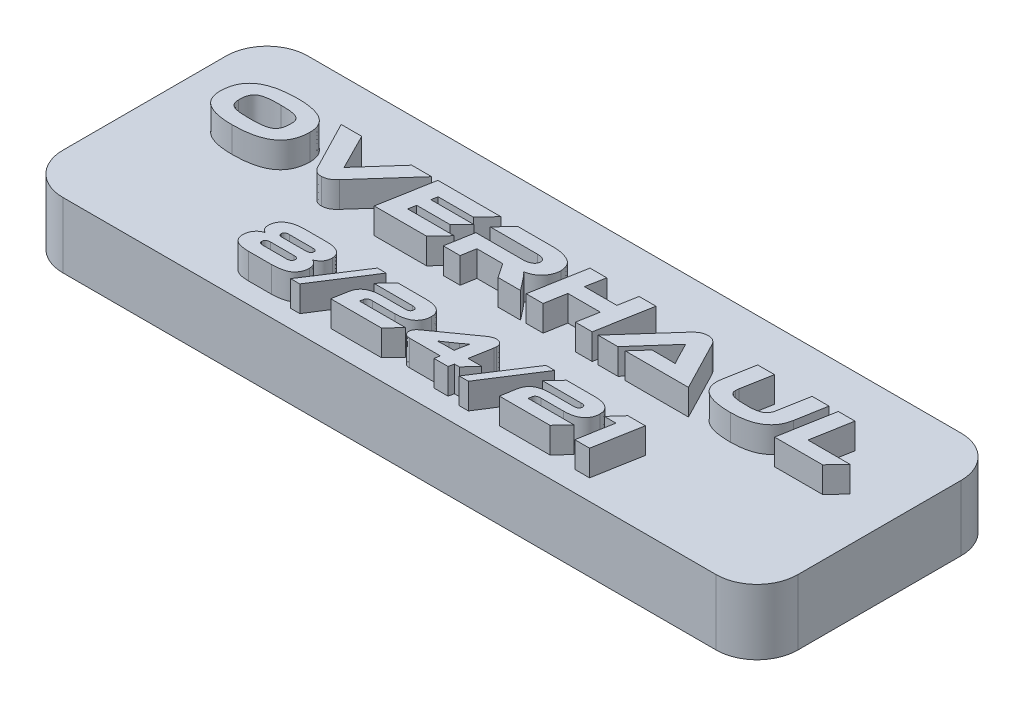
from build123d import *

# Parameters (mm, degrees)
SKETCH1_W           = 57.15
SKETCH1_H           = 19.05
BOSS_EXTRUDE1_DEPTH = 5.08
FILLET1_R           = 3.175
BOSS_EXTRUDE2_DEPTH = 2
SKETCH4_R           = 0.9
CUT_EXTRUDE1_DEPTH  = 4


with BuildPart() as part:
    # Sketch1 → Boss-Extrude1 (new body)
    with BuildSketch(Plane(origin=(0, 0, 0), x_dir=(1, 0, 0), z_dir=(0, 1, 0))):
        Rectangle(SKETCH1_W, SKETCH1_H)
    extrude(amount=BOSS_EXTRUDE1_DEPTH)

    # Fillet1
    fillet1_edges = [part.edges().sort_by_distance(p)[0] for p in [
        (-28.575, 2.54, -9.525),
        (-28.575, 2.54, 9.525),
        (28.575, 2.54, 9.525),
        (28.575, 2.54, -9.525),
    ]]
    fillet(fillet1_edges, radius=FILLET1_R)

    # Sketch3 → Boss-Extrude2 (add)
    with BuildSketch(Plane(origin=(0, 5.08, 0), x_dir=(1, 0, 0), z_dir=(0, 1, 0))):
        Polygon((21.904636604, 1.105536066), (22.460685417, 4.208766837), (21.159025697, 4.208766837), (20.407096052, 0.006075914), (24.141469328, 0.006075914), (25.184060852, 1.105536066), align=None)
        with BuildLine():
            Line((20.442064251, 4.208766837), (19.127767057, 4.208766837))
            Line((19.127767057, 4.208766837), (18.704411711, 1.862388219))
            add(Edge.make_bspline(
                [(18.704411711, 1.862388219), (18.697687187, 1.827139312), (18.684654402, 1.758823487), (18.656333037, 1.660431879), (18.619027642, 1.570400798), (18.573699748, 1.487363307), (18.519777, 1.412619114), (18.457889435, 1.344995689), (18.387796129, 1.285307175), (18.309190758, 1.232427909), (18.219374333, 1.187314428), (18.117870887, 1.147991514), (18.002759909, 1.116850242), (17.875153325, 1.090400749), (17.73446191, 1.069568326), (17.580667265, 1.055333672), (17.413824815, 1.047035371), (17.298252538, 1.046819269), (17.238213092, 1.046707005)],
                knots=[0, 0, 0, 0, 0.000107621, 0.000208581, 0.000306536, 0.000399412, 0.000491759, 0.000582339, 0.000673759, 0.000767316, 0.000865846, 0.000974664, 0.001093329, 0.001223132, 0.001365473, 0.001519746, 0.001686326, 0.001866423, 0.001866423, 0.001866423, 0.001866423], degree=3))
            add(Edge.make_bspline(
                [(17.238213092, 1.046707005), (17.169950394, 1.046621121), (17.038884397, 1.046456221), (16.850538645, 1.052429953), (16.678498084, 1.060533552), (16.523041839, 1.075472065), (16.384262724, 1.093422131), (16.261547536, 1.114517759), (16.15566669, 1.141999094), (16.064276341, 1.172526408), (15.987045543, 1.209629908), (15.920884102, 1.251845467), (15.865525046, 1.30043275), (15.820735287, 1.354972316), (15.787254953, 1.415773277), (15.764123896, 1.4824615), (15.75234608, 1.555465653), (15.752587531, 1.605828027), (15.752711884, 1.631765942)],
                knots=[0, 0, 0, 0, 0.000204773, 0.000393168, 0.000565272, 0.000721365, 0.000861515, 0.000985061, 0.001094592, 0.001189417, 0.001273644, 0.00135098, 0.001424164, 0.001493694, 0.001561619, 0.001631293, 0.001704482, 0.001782207, 0.001782207, 0.001782207, 0.001782207], degree=3))
            add(Edge.make_bspline(
                [(15.752711884, 1.631765942), (15.753573907, 1.668081018), (15.755405459, 1.745240135), (15.766196769, 1.821673195), (15.77190913, 1.862132899)],
                knots=[0, 0, 0, 0, 0.00010888, 0.00023134, 0.00023134, 0.00023134, 0.00023134], degree=3))
            Line((15.77190913, 1.862132899), (16.202192054, 4.208766837))
            Line((16.202192054, 4.208766837), (14.894213597, 4.208766837))
            Line((14.894213597, 4.208766837), (14.470858251, 1.862388219))
            add(Edge.make_bspline(
                [(14.470858251, 1.862388219), (14.459517189, 1.795424142), (14.437513802, 1.665503639), (14.434252842, 1.533787249), (14.432672657, 1.46996058)],
                knots=[0, 0, 0, 0, 0.000203453, 0.00039473, 0.00039473, 0.00039473, 0.00039473], degree=3))
            add(Edge.make_bspline(
                [(14.432672657, 1.46996058), (14.43387161, 1.40859245), (14.436205976, 1.289108399), (14.465425441, 1.115562884), (14.513284004, 0.953539335), (14.583011741, 0.803554728), (14.67195073, 0.665184035), (14.782704836, 0.540177804), (14.911738014, 0.425561456), (15.062393294, 0.324145254), (15.233636323, 0.234151547), (15.427444459, 0.15809302), (15.642905635, 0.09238014), (15.881057591, 0.039293588), (16.141111837, -0.002721651), (16.423517594, -0.030740825), (16.728165043, -0.049583047), (16.938948754, -0.051848282), (17.048068937, -0.053020966)],
                knots=[0, 0, 0, 0, 0.000183929, 0.000358111, 0.000526139, 0.000689333, 0.000852629, 0.001017828, 0.001188792, 0.001369069, 0.001561259, 0.001768019, 0.001992702, 0.002236425, 0.002499429, 0.002782504, 0.003087466, 0.003414796, 0.003414796, 0.003414796, 0.003414796], degree=3))
            add(Edge.make_bspline(
                [(17.048068937, -0.053020966), (17.155069055, -0.051404013), (17.363226566, -0.0482584), (17.666249847, -0.025020937), (17.951508656, 0.011650769), (18.218753707, 0.064516757), (18.468170696, 0.131877218), (18.699745928, 0.213665603), (18.912822065, 0.311958663), (19.108558509, 0.424179889), (19.286111022, 0.552059501), (19.446493896, 0.694108361), (19.587957265, 0.852282745), (19.710910661, 1.025501425), (19.817027583, 1.21259616), (19.902209005, 1.415894135), (19.973306285, 1.632639003), (20.003011476, 1.784635018), (20.018157198, 1.862132899)],
                knots=[0, 0, 0, 0, 0.000320974, 0.000624421, 0.000911183, 0.001183331, 0.001441019, 0.001685636, 0.00191919, 0.002144039, 0.002361465, 0.002574487, 0.002785536, 0.002996585, 0.003210663, 0.003429366, 0.003656887, 0.00389357, 0.00389357, 0.00389357, 0.00389357], degree=3))
            Line((20.018157198, 1.862132899), (20.442064251, 4.208766837))
        make_face()
        with BuildLine():
            Line((13.713425825, 0.006075914), (11.748298771, 3.800574494))
            add(Edge.make_bspline(
                [(11.748298771, 3.800574494), (11.730177827, 3.832806008), (11.694219163, 3.896765269), (11.629345474, 3.985575321), (11.552085987, 4.0630874), (11.467183075, 4.133983071), (11.369377181, 4.192399523), (11.257266032, 4.23493807), (11.131224204, 4.260058315), (11.042493271, 4.264204191), (10.996365556, 4.266359469)],
                knots=[0, 0, 0, 0, 0.000110886, 0.000220038, 0.000328642, 0.000438436, 0.000551159, 0.000668641, 0.000796469, 0.000934872, 0.000934872, 0.000934872, 0.000934872], degree=3))
            add(Edge.make_bspline(
                [(10.996365556, 4.266359469), (10.946553896, 4.264009128), (10.849822775, 4.259444915), (10.709784019, 4.230967468), (10.579505457, 4.187726952), (10.459770582, 4.126959855), (10.350088926, 4.055096369), (10.246887573, 3.977511138), (10.15258136, 3.892229282), (10.095198857, 3.830720556), (10.066670338, 3.800140628)],
                knots=[0, 0, 0, 0, 0.00014941, 0.000290146, 0.000427171, 0.000560039, 0.000691642, 0.000820174, 0.000947034, 0.001072464, 0.001072464, 0.001072464, 0.001072464], degree=3))
            Line((10.066670338, 3.800140628), (6.680672092, 0.006075914))
            Line((6.680672092, 0.006075914), (8.228762536, 0.006075914))
            Line((8.228762536, 0.006075914), (10.705707247, 2.798493231))
            Line((10.705707247, 2.798493231), (11.268074796, 1.696826253))
            add(Edge.make_bspline(
                [(11.268074796, 1.696826253), (11.294748801, 1.644325557), (11.349265048, 1.5370248), (11.418693389, 1.403208105), (11.474776483, 1.297464771), (11.515917598, 1.223921613), (11.552321439, 1.155498073), (11.577619745, 1.112747401), (11.589651884, 1.092414734)],
                knots=[0, 0, 0, 0, 0.000176664, 0.000361065, 0.000452265, 0.000535729, 0.000613867, 0.000684736, 0.000684736, 0.000684736, 0.000684736], degree=3))
            add(Edge.make_bspline(
                [(11.589651884, 1.092414734), (11.534203539, 1.095166522), (11.416043704, 1.101030553), (11.231613169, 1.103502684), (11.036594303, 1.10564963), (10.904341706, 1.105358474), (10.838216812, 1.105212899)],
                knots=[0, 0, 0, 0, 0.000166537, 0.000354888, 0.000553268, 0.00075164, 0.00075164, 0.00075164, 0.00075164], degree=3))
            Line((10.838216812, 1.105212899), (9.783171717, 1.105536066))
            Line((9.783171717, 1.105536066), (8.797448822, 0.006075914))
            Line((8.797448822, 0.006075914), (13.713425825, 0.006075914))
        make_face()
        Polygon((6.982894813, 4.208766837), (5.674916356, 4.208766837), (5.409529423, 2.743700198), (2.888353556, 2.743700198), (3.160059226, 4.208766837), (1.852080769, 4.208766837), (1.100151125, 0.003655726), (2.414448318, 0.003655726), (2.698791461, 1.644240046), (5.219967327, 1.644240046), (4.929305448, 0.003655726), (6.230965169, 0.003655726), align=None)
        with BuildLine():
            add(Edge.make_bspline(
                [(0.022791374, 0.821261664), (-0.004994751, 0.855514425), (-0.057904322, 0.920737585), (-0.131689663, 1.014147602), (-0.200292848, 1.094728322), (-0.260658939, 1.165931133), (-0.316640074, 1.228233858), (-0.36814445, 1.283693514), (-0.416727333, 1.332710365), (-0.449031208, 1.361916294), (-0.464390531, 1.375802657)],
                knots=[0, 0, 0, 0, 0.000132319, 0.000251958, 0.000357066, 0.000449775, 0.000531993, 0.000608312, 0.000676831, 0.00073894, 0.00073894, 0.00073894, 0.00073894], degree=3))
            add(Edge.make_bspline(
                [(-0.464390531, 1.375802657), (-0.413945609, 1.387655917), (-0.314612899, 1.41099655), (-0.170645879, 1.456505146), (-0.034807147, 1.512656797), (0.093162396, 1.577599655), (0.213949002, 1.650662326), (0.325673422, 1.734287933), (0.429411301, 1.827209607), (0.524966768, 1.928008098), (0.610833583, 2.036209783), (0.687047191, 2.148795776), (0.750293461, 2.26744033), (0.803959406, 2.389702633), (0.844461788, 2.517720245), (0.876615568, 2.649747841), (0.894225263, 2.787111939), (0.898356707, 2.88015474), (0.900442271, 2.927122995)],
                knots=[0, 0, 0, 0, 0.000155422, 0.000306047, 0.000452383, 0.000595882, 0.000736201, 0.000875336, 0.001013884, 0.001153561, 0.001291475, 0.00142788, 0.00156081, 0.001694289, 0.00182785, 0.001963107, 0.002101444, 0.002242464, 0.002242464, 0.002242464, 0.002242464], degree=3))
            add(Edge.make_bspline(
                [(0.900442271, 2.927122995), (0.895778624, 2.986733362), (0.886779663, 3.101757358), (0.850373496, 3.266295736), (0.797787855, 3.416602664), (0.72682639, 3.55250609), (0.638298171, 3.674215745), (0.530496428, 3.779555576), (0.407150888, 3.872802597), (0.265519129, 3.946152329), (0.115725482, 4.009923214), (-0.038563888, 4.066098529), (-0.196681704, 4.111445148), (-0.357669337, 4.149301444), (-0.522236672, 4.17747869), (-0.689778911, 4.196572697), (-0.860386404, 4.207081738), (-0.975084963, 4.20637971), (-1.032994686, 4.206025266)],
                knots=[0, 0, 0, 0, 0.000179195, 0.000345775, 0.000503934, 0.000655634, 0.000804102, 0.000953423, 0.00110627, 0.001266195, 0.001430402, 0.00159465, 0.001758393, 0.001923592, 0.002090563, 0.002258951, 0.002429281, 0.002602973, 0.002602973, 0.002602973, 0.002602973], degree=3))
            Line((-1.032994686, 4.206025266), (-3.749494321, 4.206347541))
            Line((-3.749494321, 4.206347541), (-4.798404581, 3.106887389))
            Line((-4.798404581, 3.106887389), (-1.120899934, 3.106887389))
            add(Edge.make_bspline(
                [(-1.120899934, 3.106887389), (-1.072938384, 3.105563142), (-0.982126628, 3.103055777), (-0.854021817, 3.084102014), (-0.742401524, 3.053127658), (-0.648041951, 3.008361144), (-0.571875632, 2.950733271), (-0.51613922, 2.878524615), (-0.482912556, 2.792039639), (-0.479147209, 2.729960255), (-0.477188696, 2.697670193)],
                knots=[0, 0, 0, 0, 0.000143839, 0.000272348, 0.000387495, 0.000490117, 0.000583924, 0.00067132, 0.000760449, 0.00085706, 0.00085706, 0.00085706, 0.00085706], degree=3))
            add(Edge.make_bspline(
                [(-0.477188696, 2.697670193), (-0.478865735, 2.677195647), (-0.482173726, 2.636809238), (-0.494954964, 2.578009425), (-0.515063441, 2.522994029), (-0.542454382, 2.47158108), (-0.575845759, 2.423095084), (-0.617782693, 2.378841184), (-0.666800829, 2.338813063), (-0.740479044, 2.288346001), (-0.845093422, 2.236864834), (-0.982572599, 2.191707585), (-1.133178036, 2.165412454), (-1.237662961, 2.161339559), (-1.291700435, 2.15923314)],
                knots=[0, 0, 0, 0, 6.1582e-05, 0.000121471, 0.000179891, 0.000236731, 0.000295819, 0.000355966, 0.000418937, 0.000485369, 0.000623551, 0.000766937, 0.000918284, 0.001080402, 0.001080402, 0.001080402, 0.001080402], degree=3))
            Line((-1.291700435, 2.15923314), (-4.969010467, 2.159459893))
            Line((-4.969010467, 2.159459893), (-5.348134658, 0.003655726))
            Line((-5.348134658, 0.003655726), (-4.040156201, 0.003655726))
            Line((-4.040156201, 0.003655726), (-3.844275369, 1.11686837))
            Line((-3.844275369, 1.11686837), (-1.834917159, 1.11686837))
            Line((-1.834917159, 1.11686837), (-1.089306252, 0.003655726))
            Line((-1.089306252, 0.003655726), (0.660983761, 0.003655726))
            Line((0.660983761, 0.003655726), (0.022791374, 0.821261664))
        make_face()
        Polygon((-9.214180118, 1.105536066), (-9.113080334, 1.700326644), (-6.509760893, 1.700326644), (-5.599862836, 2.629107706), (-8.942474448, 2.629107706), (-8.854012137, 3.106887389), (-6.117999229, 3.106887389), (-5.075407706, 4.206347541), (-9.966109762, 4.206347541), (-10.718039407, 0.006075914), (-6.648773096, 0.006075914), (-5.612500309, 1.105536066), align=None)
        with BuildLine():
            Line((-17.490908988, 4.208766837), (-15.525781935, 0.415372562))
            add(Edge.make_bspline(
                [(-15.525781935, 0.415372562), (-15.508050787, 0.382479631), (-15.473037945, 0.317527547), (-15.4071602, 0.228997354), (-15.33127617, 0.149963013), (-15.246514412, 0.078477155), (-15.148276801, 0.019758241), (-15.035586647, -0.022115586), (-14.909528353, -0.048687381), (-14.820715584, -0.053343833), (-14.774566473, -0.05576343)],
                knots=[0, 0, 0, 0, 0.000111991, 0.000221144, 0.000329771, 0.000440145, 0.000552868, 0.000671204, 0.000799219, 0.000937691, 0.000937691, 0.000937691, 0.000937691], degree=3))
            add(Edge.make_bspline(
                [(-14.774566473, -0.05576343), (-14.724766829, -0.052994881), (-14.627782225, -0.047603143), (-14.48761636, -0.019769924), (-14.357242834, 0.02385057), (-14.237962772, 0.085532414), (-14.128203214, 0.158182508), (-14.025425378, 0.236849256), (-13.930488306, 0.321749072), (-13.873915254, 0.384048841), (-13.845785411, 0.415026184)],
                knots=[0, 0, 0, 0, 0.00014948, 0.000291112, 0.000427272, 0.000560551, 0.000692652, 0.000821739, 0.000948599, 0.001074061, 0.001074061, 0.001074061, 0.001074061], degree=3))
            Line((-13.845785411, 0.415026184), (-10.458155256, 4.208766837))
            Line((-10.458155256, 4.208766837), (-12.0062457, 4.208766837))
            Line((-12.0062457, 4.208766837), (-14.483190411, 1.424784024))
            Line((-14.483190411, 1.424784024), (-15.892268652, 4.208766837))
            Line((-15.892268652, 4.208766837), (-17.490908988, 4.208766837))
        make_face()
        with BuildLine():
            add(Edge.make_bspline(
                [(-20.927025046, 4.264853435), (-21.00009776, 4.264150041), (-21.143601871, 4.262768679), (-21.355063502, 4.255304453), (-21.55933924, 4.243828802), (-21.756533388, 4.226275073), (-21.946760701, 4.204448808), (-22.130065277, 4.178135377), (-22.306362027, 4.146346882), (-22.475499423, 4.108703546), (-22.637475523, 4.066841285), (-22.792338087, 4.020018599), (-22.940547846, 3.969271115), (-23.081806941, 3.912462076), (-23.21570116, 3.850145336), (-23.343470625, 3.784672178), (-23.463519889, 3.713307743), (-23.576008698, 3.636054084), (-23.682534531, 3.555015487), (-23.78125525, 3.467997248), (-23.873108766, 3.375795294), (-23.959180076, 3.27972572), (-24.036921174, 3.176938462), (-24.109606416, 3.070861845), (-24.173047187, 2.958180712), (-24.232575897, 2.842029764), (-24.283268707, 2.71956376), (-24.326986557, 2.592115874), (-24.364923815, 2.460138961), (-24.394589245, 2.322911611), (-24.418464623, 2.180763117), (-24.435794158, 2.033740252), (-24.446118596, 1.881481624), (-24.446859522, 1.778351657), (-24.447236184, 1.725923865)],
                knots=[0, 0, 0, 0, 0.00021922, 0.000430517, 0.000634719, 0.000832939, 0.001024345, 0.001209088, 0.001388397, 0.001561619, 0.0017288, 0.001890173, 0.002046865, 0.002198625, 0.002346687, 0.00248979, 0.002629165, 0.002765325, 0.002898982, 0.003030471, 0.003159752, 0.003289265, 0.003417071, 0.003546125, 0.003674706, 0.003804712, 0.003937476, 0.004071906, 0.004208776, 0.004349179, 0.004492852, 0.004641052, 0.004793135, 0.004950393, 0.004950393, 0.004950393, 0.004950393], degree=3))
            add(Edge.make_bspline(
                [(-24.447236184, 1.725923865), (-24.445307742, 1.652651179), (-24.441566524, 1.510500548), (-24.407527654, 1.304743113), (-24.3543388, 1.113533359), (-24.278641875, 0.936607339), (-24.181089217, 0.774301847), (-24.06125441, 0.627005612), (-23.919297146, 0.495143384), (-23.756407561, 0.377875494), (-23.571969391, 0.275513814), (-23.366545115, 0.187096535), (-23.140360604, 0.111278664), (-22.892532815, 0.05083109), (-22.624087172, 0.003624777), (-22.334401862, -0.029580863), (-22.023495359, -0.049844784), (-21.809018391, -0.051940053), (-21.698373333, -0.053020966)],
                knots=[0, 0, 0, 0, 0.000219671, 0.000426167, 0.000623813, 0.000813827, 0.001001645, 0.001190103, 0.001381548, 0.00158123, 0.001790776, 0.002013083, 0.002251287, 0.002505594, 0.002777627, 0.003068474, 0.003379936, 0.003711836, 0.003711836, 0.003711836, 0.003711836], degree=3))
            add(Edge.make_bspline(
                [(-21.698373333, -0.053020966), (-21.625538667, -0.052455169), (-21.482270661, -0.051342229), (-21.270750047, -0.043724787), (-21.06646016, -0.032438481), (-20.869292668, -0.014624257), (-20.678970802, 0.006825126), (-20.49579905, 0.034388638), (-20.319463816, 0.066140884), (-20.150597896, 0.103671999), (-19.988417163, 0.145843098), (-19.832905685, 0.191939017), (-19.68486263, 0.24436261), (-19.543586925, 0.30061376), (-19.410003746, 0.363320067), (-19.282591949, 0.429548791), (-19.162841526, 0.501958418), (-19.050063375, 0.579052293), (-18.943633258, 0.660209293), (-18.844528177, 0.747143393), (-18.753319362, 0.84029394), (-18.666891877, 0.93631177), (-18.589196176, 1.03914999), (-18.516538914, 1.145233071), (-18.452806255, 1.258074334), (-18.393784926, 1.374784654), (-18.342807579, 1.497412041), (-18.299135236, 1.624884051), (-18.261200028, 1.756856749), (-18.231413982, 1.894369804), (-18.207745569, 2.036857562), (-18.190303388, 2.184166254), (-18.180000167, 2.336428379), (-18.179256314, 2.439557863), (-18.178878164, 2.491985411)],
                knots=[0, 0, 0, 0, 0.0002185, 0.000429796, 0.000634912, 0.000832221, 0.001023627, 0.001209407, 0.001387817, 0.001561039, 0.001728219, 0.001890468, 0.002047461, 0.002199222, 0.002346454, 0.00248998, 0.002629824, 0.002765984, 0.002899642, 0.003031131, 0.00316106, 0.003290573, 0.003418378, 0.003547433, 0.003676014, 0.003806837, 0.003939601, 0.004074031, 0.004210901, 0.004351303, 0.004495879, 0.004644079, 0.004796161, 0.00495342, 0.00495342, 0.00495342, 0.00495342], degree=3))
            add(Edge.make_bspline(
                [(-18.178878164, 2.491985411), (-18.180959096, 2.564930001), (-18.185011537, 2.706983534), (-18.217142892, 2.912703512), (-18.271140178, 3.104122883), (-18.347129198, 3.280748696), (-18.44508266, 3.44245971), (-18.564221655, 3.589369287), (-18.70563089, 3.721034434), (-18.869142824, 3.837071522), (-19.053175604, 3.940135668), (-19.259218181, 4.0266221), (-19.485084986, 4.102333874), (-19.733102972, 4.161421518), (-20.00172148, 4.208718585), (-20.291677839, 4.242297194), (-20.60265844, 4.261022072), (-20.817102838, 4.263336881), (-20.927025046, 4.264853435)],
                knots=[0, 0, 0, 0, 0.000218758, 0.000426013, 0.00062278, 0.000813995, 0.001001031, 0.001188203, 0.001379648, 0.001578795, 0.001788342, 0.002011126, 0.002248172, 0.002502261, 0.002775194, 0.003066041, 0.003377445, 0.003709345, 0.003709345, 0.003709345, 0.003709345], degree=3))
        make_face()
        with BuildLine():
            add(Edge.make_bspline(
                [(-21.508348804, 1.047030173), (-21.576869442, 1.04660261), (-21.708788696, 1.045779446), (-21.899648519, 1.049733712), (-22.075812928, 1.061186797), (-22.23791658, 1.075736974), (-22.385584603, 1.097737934), (-22.518911321, 1.125013299), (-22.638751052, 1.156348623), (-22.744616661, 1.194530349), (-22.838465358, 1.240026498), (-22.918360742, 1.297252332), (-22.986966727, 1.363776891), (-23.040869713, 1.441900597), (-23.083739663, 1.529303822), (-23.113564373, 1.627061382), (-23.131149478, 1.735031597), (-23.132158044, 1.81026116), (-23.132681884, 1.849334734)],
                knots=[0, 0, 0, 0, 0.000205565, 0.000395764, 0.000572537, 0.000735087, 0.000883892, 0.001020147, 0.001143219, 0.001255139, 0.001357344, 0.001455005, 0.001548736, 0.001642574, 0.001738242, 0.001839729, 0.001948086, 0.002065187, 0.002065187, 0.002065187, 0.002065187], degree=3))
            add(Edge.make_bspline(
                [(-23.132681884, 1.849334734), (-23.134330404, 1.911811071), (-23.137486254, 2.031412847), (-23.125588469, 2.203375738), (-23.100627455, 2.359667266), (-23.061778776, 2.50079582), (-23.008513485, 2.626166729), (-22.942948871, 2.737052728), (-22.861136723, 2.83042282), (-22.781930642, 2.895436203), (-22.711279894, 2.940784123), (-22.650782812, 2.971515459), (-22.583692287, 2.999666566), (-22.51042743, 3.026084681), (-22.430909795, 3.05083148), (-22.344852997, 3.072755525), (-22.251912895, 3.09131218), (-22.152820496, 3.110411596), (-22.046486912, 3.124111193), (-21.934104714, 3.137374608), (-21.814853701, 3.147018552), (-21.689292346, 3.155167115), (-21.557042952, 3.161792983), (-21.418358802, 3.165320712), (-21.272985167, 3.166041701), (-21.173952762, 3.165221911), (-21.123370097, 3.164803188)],
                knots=[0, 0, 0, 0, 0.000187411, 0.00035877, 0.00051627, 0.000661555, 0.000796714, 0.00092386, 0.001046319, 0.001167112, 0.001230003, 0.001297872, 0.001370374, 0.001448163, 0.001531436, 0.001620123, 0.001714428, 0.001815734, 0.00192278, 0.002035947, 0.002155212, 0.002281633, 0.002413427, 0.002552426, 0.00269778, 0.002849532, 0.002849532, 0.002849532, 0.002849532], degree=3))
            add(Edge.make_bspline(
                [(-21.123370097, 3.164803188), (-21.054504847, 3.165086646), (-20.921327, 3.165634822), (-20.728904532, 3.161832074), (-20.551211942, 3.150341942), (-20.387916979, 3.135653139), (-20.239267652, 3.114010286), (-20.105133317, 3.086275793), (-19.985099312, 3.055550786), (-19.879479185, 3.01670025), (-19.785930657, 2.971781209), (-19.706686234, 2.913989507), (-19.638360181, 2.847457656), (-19.583162772, 2.770130915), (-19.541516519, 2.682069422), (-19.512759707, 2.584313015), (-19.494901811, 2.476491904), (-19.493934748, 2.401253582), (-19.493432464, 2.362175459)],
                knots=[0, 0, 0, 0, 0.000206599, 0.00039954, 0.000577225, 0.000740685, 0.000891298, 0.001027553, 0.001151508, 0.001262569, 0.001364775, 0.001461693, 0.001555424, 0.00164979, 0.00174506, 0.001846279, 0.001954636, 0.002071737, 0.002071737, 0.002071737, 0.002071737], degree=3))
            add(Edge.make_bspline(
                [(-19.493432464, 2.362175459), (-19.49181009, 2.300007823), (-19.488704956, 2.181022384), (-19.500276656, 2.009565903), (-19.526503449, 1.85401663), (-19.565436613, 1.713235889), (-19.61833124, 1.587793863), (-19.685099404, 1.477427264), (-19.767128397, 1.383606431), (-19.84659497, 1.317707612), (-19.918333377, 1.272767382), (-19.979178401, 1.241979786), (-20.04584798, 1.212524455), (-20.11963264, 1.186264377), (-20.199498632, 1.161664348), (-20.286241969, 1.139884782), (-20.379158667, 1.119635522), (-20.47899588, 1.102726509), (-20.584997814, 1.086938186), (-20.697815062, 1.074209563), (-20.817051568, 1.064550242), (-20.942913099, 1.056272217), (-21.075167286, 1.049750773), (-21.214154314, 1.046182113), (-21.359528347, 1.045470465), (-21.458560697, 1.046288949), (-21.508348804, 1.047030173)],
                knots=[0, 0, 0, 0, 0.000186496, 0.000356944, 0.000514595, 0.000659, 0.000794159, 0.000921781, 0.00104424, 0.00116632, 0.001229983, 0.001297853, 0.001370716, 0.001448505, 0.001532652, 0.001621339, 0.001716727, 0.001817873, 0.001925047, 0.002038214, 0.00215839, 0.002283899, 0.002416606, 0.002555606, 0.002700959, 0.002852711, 0.002852711, 0.002852711, 0.002852711], degree=3))
        make_face(mode=Mode.SUBTRACT)
        Polygon((12.398460647, -5.218973535), (13.299670441, -5.218973535), (12.818656624, -7.93430124), (13.963137774, -7.93430124), (14.621076213, -4.256945902), (13.266497074, -4.256945902), align=None)
        with BuildLine():
            Line((7.581851533, -5.218973535), (10.572983428, -5.218973535))
            add(Edge.make_bspline(
                [(10.572983428, -5.218973535), (10.600684342, -5.218922741), (10.652530716, -5.218827674), (10.725259719, -5.225918073), (10.786783761, -5.242216387), (10.838614298, -5.26353583), (10.878707687, -5.294908436), (10.907021686, -5.334273792), (10.924573664, -5.381008794), (10.925798363, -5.4147712), (10.926432729, -5.432259348)],
                knots=[0, 0, 0, 0, 8.3099e-05, 0.000155531, 0.000218392, 0.000273538, 0.000322508, 0.000368908, 0.000417497, 0.000469711, 0.000469711, 0.000469711, 0.000469711], degree=3))
            add(Edge.make_bspline(
                [(10.926432729, -5.432259348), (10.925792936, -5.458018948), (10.924583331, -5.506720508), (10.904020946, -5.573936821), (10.87073457, -5.630194031), (10.821520946, -5.673414306), (10.757989848, -5.704561408), (10.680255681, -5.726311626), (10.587130521, -5.738498194), (10.520128877, -5.73961472), (10.484096178, -5.740215175)],
                knots=[0, 0, 0, 0, 7.6993e-05, 0.000145564, 0.000208395, 0.000270703, 0.000339032, 0.00041902, 0.000511893, 0.000619952, 0.000619952, 0.000619952, 0.000619952], degree=3))
            Line((10.484096178, -5.740215175), (8.726332683, -5.739416071))
            add(Edge.make_bspline(
                [(8.726332683, -5.739416071), (8.670730527, -5.740560639), (8.562477365, -5.742789025), (8.404482039, -5.753609346), (8.255762679, -5.772857955), (8.116139811, -5.798779792), (7.985876613, -5.833149331), (7.864797761, -5.875619954), (7.752530381, -5.92500466), (7.649328513, -5.98174212), (7.555859317, -6.047028209), (7.471333824, -6.120143527), (7.395933215, -6.201107035), (7.329932192, -6.289606037), (7.273550619, -6.385733808), (7.226454864, -6.489539314), (7.187507501, -6.600822081), (7.170185825, -6.678800473), (7.161372784, -6.718474855)],
                knots=[0, 0, 0, 0, 0.000166829, 0.000324804, 0.000474816, 0.000616477, 0.000750546, 0.000878553, 0.001001026, 0.001118108, 0.001231277, 0.001342418, 0.001452782, 0.001562526, 0.00167296, 0.001786425, 0.001904052, 0.002025887, 0.002025887, 0.002025887, 0.002025887], degree=3))
            Line((7.161372784, -6.718474855), (6.946028672, -7.932183575))
            Line((6.946028672, -7.932183575), (10.882601517, -7.932183575))
            Line((10.882601517, -7.932183575), (11.789340205, -6.970155942))
            Line((11.789340205, -6.970155942), (8.217674395, -6.970155942))
            Line((8.217674395, -6.970155942), (8.267434445, -6.707239748))
            add(Edge.make_bspline(
                [(8.267434445, -6.707239748), (8.271211968, -6.686112106), (8.278534725, -6.645156023), (8.307246078, -6.590591717), (8.345606771, -6.543848716), (8.396946103, -6.508043577), (8.45802157, -6.47963759), (8.53033919, -6.461031101), (8.613402611, -6.450993538), (8.672326121, -6.450679637), (8.703551576, -6.450513291)],
                knots=[0, 0, 0, 0, 6.4036e-05, 0.000124134, 0.000182613, 0.000243892, 0.000310094, 0.000383827, 0.000466868, 0.000560486, 0.000560486, 0.000560486, 0.000560486], degree=3))
            Line((8.703551576, -6.450513291), (10.462405539, -6.449714187))
            add(Edge.make_bspline(
                [(10.462405539, -6.449714187), (10.528086564, -6.448593152), (10.655421004, -6.446419826), (10.839318853, -6.426694059), (11.010735464, -6.400940141), (11.16858235, -6.361961645), (11.314336343, -6.315052912), (11.445677598, -6.255202462), (11.565150714, -6.187512089), (11.669863153, -6.107690588), (11.762446345, -6.020066732), (11.842902707, -5.925525662), (11.910681592, -5.823724541), (11.966434393, -5.715194429), (12.008570363, -5.599220599), (12.039265799, -5.476792913), (12.056921144, -5.347458364), (12.058874098, -5.259004345), (12.059870151, -5.21389067)],
                knots=[0, 0, 0, 0, 0.00019697, 0.000381861, 0.000554393, 0.000716581, 0.000869107, 0.001013024, 0.00114885, 0.001280192, 0.001406932, 0.001530654, 0.001651783, 0.001773055, 0.001895792, 0.002021116, 0.002151095, 0.002286391, 0.002286391, 0.002286391, 0.002286391], degree=3))
            add(Edge.make_bspline(
                [(12.059870151, -5.21389067), (12.059417696, -5.1780961), (12.058531951, -5.108023129), (12.042322104, -5.005989197), (12.018330032, -4.909275966), (11.981795329, -4.818686266), (11.934160976, -4.734234215), (11.876081934, -4.655338408), (11.807714307, -4.582231577), (11.728419867, -4.515185386), (11.63759695, -4.455053695), (11.534018329, -4.402688892), (11.417785209, -4.359688685), (11.28959773, -4.322394884), (11.148794721, -4.294289614), (10.995447675, -4.27367202), (10.829581144, -4.26108405), (10.714751529, -4.258543735), (10.655271624, -4.257227893)],
                knots=[0, 0, 0, 0, 0.000107259, 0.000209975, 0.000309113, 0.00040566, 0.000501999, 0.00059927, 0.000698874, 0.0008016, 0.000910084, 0.001024914, 0.001148961, 0.001281358, 0.001425053, 0.00157924, 0.00174531, 0.001923772, 0.001923772, 0.001923772, 0.001923772], degree=3))
            Line((10.655271624, -4.257227893), (8.488590222, -4.256945902))
            Line((8.488590222, -4.256945902), (7.581851533, -5.218973535))
        make_face()
        Polygon((6.696041093, -4.05005839), (4.031113971, -8.139071868), (4.744341354, -8.139071868), (7.370566215, -4.05005839), align=None)
        with BuildLine():
            Line((1.947009786, -7.520594175), (1.869605264, -7.93430124))
            Line((1.869605264, -7.93430124), (2.964326364, -7.93430124))
            Line((2.964326364, -7.93430124), (3.041730886, -7.520594175))
            Line((3.041730886, -7.520594175), (3.428753497, -7.520594175))
            Line((3.428753497, -7.520594175), (4.258087664, -6.613855487))
            Line((4.258087664, -6.613855487), (3.196539931, -6.613855487))
            Line((3.196539931, -6.613855487), (3.500629125, -4.894612248))
            add(Edge.make_bspline(
                [(3.500629125, -4.894612248), (3.505490527, -4.864321659), (3.515179608, -4.803950598), (3.516458362, -4.742821019), (3.517095513, -4.712362609)],
                knots=[0, 0, 0, 0, 9.1912e-05, 0.000183187, 0.000183187, 0.000183187, 0.000183187], degree=3))
            add(Edge.make_bspline(
                [(3.517095513, -4.712362609), (3.516398732, -4.6907417), (3.515051864, -4.648948846), (3.50707941, -4.588663196), (3.494045039, -4.533098056), (3.477741429, -4.481981392), (3.456343952, -4.435403393), (3.43137673, -4.39290306), (3.40016358, -4.355875929), (3.354428561, -4.312019012), (3.287845421, -4.268282081), (3.199105491, -4.230068234), (3.100983382, -4.207057185), (3.032490749, -4.205327459), (2.997170091, -4.204435465)],
                knots=[0, 0, 0, 0, 6.487e-05, 0.000125392, 0.000182048, 0.000235927, 0.000286039, 0.000335561, 0.000383287, 0.000430811, 0.000525319, 0.000620267, 0.000719611, 0.000825389, 0.000825389, 0.000825389, 0.000825389], degree=3))
            add(Edge.make_bspline(
                [(2.997170091, -4.204435465), (2.97902658, -4.204980307), (2.941012498, -4.206121854), (2.880887657, -4.21327143), (2.815810204, -4.228757289), (2.74480923, -4.24699065), (2.670428384, -4.273748693), (2.593641164, -4.307912525), (2.515861983, -4.351603952), (2.465029137, -4.38540133), (2.438850175, -4.402807011)],
                knots=[0, 0, 0, 0, 5.4445e-05, 0.000114073, 0.000181225, 0.000254958, 0.000333892, 0.000418032, 0.000506833, 0.000601128, 0.000601128, 0.000601128, 0.000601128], degree=3))
            Line((2.438850175, -4.402807011), (-0.612868341, -6.56963058))
            add(Edge.make_bspline(
                [(-0.612868341, -6.56963058), (-0.63932232, -6.590810858), (-0.689925327, -6.631325964), (-0.757012334, -6.696764533), (-0.812937477, -6.7623047), (-0.859487384, -6.827079539), (-0.894316084, -6.892522378), (-0.918827901, -6.958059845), (-0.933147068, -7.023928319), (-0.933897027, -7.067959349), (-0.93426599, -7.089621618)],
                knots=[0, 0, 0, 0, 0.00010162, 0.000194386, 0.000280626, 0.000359851, 0.000433205, 0.000502297, 0.000569282, 0.000634152, 0.000634152, 0.000634152, 0.000634152], degree=3))
            add(Edge.make_bspline(
                [(-0.93426599, -7.089621618), (-0.932783617, -7.118591013), (-0.929891334, -7.175113703), (-0.905603265, -7.255822597), (-0.86721555, -7.329482478), (-0.814314576, -7.395411266), (-0.7466111, -7.450617536), (-0.663849998, -7.490141442), (-0.568267078, -7.515111941), (-0.499825794, -7.518816836), (-0.463933454, -7.520759777)],
                knots=[0, 0, 0, 0, 8.6757e-05, 0.000169273, 0.000250488, 0.000334685, 0.000421132, 0.000510207, 0.000607797, 0.00071541, 0.00071541, 0.00071541, 0.00071541], degree=3))
            Line((-0.463933454, -7.520759777), (1.947009786, -7.520594175))
        make_face()
        with BuildLine():
            Line((2.107347725, -6.613855487), (1.443880392, -6.613855487))
            add(Edge.make_bspline(
                [(1.443880392, -6.613855487), (1.380388897, -6.614087024), (1.260886946, -6.614522818), (1.093147038, -6.618813835), (0.948189101, -6.623863417), (0.859585061, -6.632252066), (0.819082512, -6.636086673)],
                knots=[0, 0, 0, 0, 0.000190466, 0.000358489, 0.00050341, 0.000625436, 0.000625436, 0.000625436, 0.000625436], degree=3))
            add(Edge.make_bspline(
                [(0.819082512, -6.636086673), (0.857896465, -6.612329849), (0.941685981, -6.561044871), (1.07276471, -6.47333578), (1.220619946, -6.372579941), (1.323171619, -6.299033186), (1.377402428, -6.260140598)],
                knots=[0, 0, 0, 0, 0.000136509, 0.000294688, 0.000473068, 0.000673265, 0.000673265, 0.000673265, 0.000673265], degree=3))
            Line((1.377402428, -6.260140598), (1.841960792, -5.93389755))
            add(Edge.make_bspline(
                [(1.841960792, -5.93389755), (1.890395865, -5.899629074), (1.981624196, -5.835083783), (2.107987188, -5.742002288), (2.214400522, -5.658449591), (2.277421481, -5.604680291), (2.306069221, -5.580238122)],
                knots=[0, 0, 0, 0, 0.000177993, 0.000335254, 0.000470796, 0.000583761, 0.000583761, 0.000583761, 0.000583761], degree=3))
            add(Edge.make_bspline(
                [(2.306069221, -5.580238122), (2.297931716, -5.612733173), (2.28083678, -5.680997438), (2.261212148, -5.769363291), (2.245663336, -5.84710273), (2.232472404, -5.912841199), (2.220398116, -5.985328058), (2.210973577, -6.035655941), (2.206083563, -6.061769052)],
                knots=[0, 0, 0, 0, 0.000100493, 0.000211112, 0.000271507, 0.000338335, 0.000412241, 0.000491941, 0.000491941, 0.000491941, 0.000491941], degree=3))
            Line((2.206083563, -6.061769052), (2.107347725, -6.613855487))
        make_face(mode=Mode.SUBTRACT)
        with BuildLine():
            Line((-5.52346866, -5.218973535), (-2.532336766, -5.218973535))
            add(Edge.make_bspline(
                [(-2.532336766, -5.218973535), (-2.504635852, -5.218922741), (-2.452789477, -5.218827674), (-2.380060474, -5.225918073), (-2.318536432, -5.242216387), (-2.266705896, -5.26353583), (-2.226612506, -5.294908436), (-2.198298507, -5.334273792), (-2.180746529, -5.381008794), (-2.17952183, -5.4147712), (-2.178887464, -5.432259348)],
                knots=[0, 0, 0, 0, 8.3099e-05, 0.000155531, 0.000218392, 0.000273538, 0.000322508, 0.000368908, 0.000417497, 0.000469711, 0.000469711, 0.000469711, 0.000469711], degree=3))
            add(Edge.make_bspline(
                [(-2.178887464, -5.432259348), (-2.179527257, -5.458018948), (-2.180736862, -5.506720508), (-2.201299247, -5.573936821), (-2.234585624, -5.630194031), (-2.283799247, -5.673414306), (-2.347330346, -5.704561408), (-2.425064512, -5.726311626), (-2.518189672, -5.738498194), (-2.585191316, -5.73961472), (-2.621224016, -5.740215175)],
                knots=[0, 0, 0, 0, 7.6993e-05, 0.000145564, 0.000208395, 0.000270703, 0.000339032, 0.00041902, 0.000511893, 0.000619952, 0.000619952, 0.000619952, 0.000619952], degree=3))
            Line((-2.621224016, -5.740215175), (-4.37898751, -5.739416071))
            add(Edge.make_bspline(
                [(-4.37898751, -5.739416071), (-4.434589666, -5.740560639), (-4.542842828, -5.742789025), (-4.700838154, -5.753609346), (-4.849557514, -5.772857955), (-4.989180382, -5.798779792), (-5.11944358, -5.833149331), (-5.240522432, -5.875619954), (-5.352789812, -5.92500466), (-5.45599168, -5.98174212), (-5.549460877, -6.047028209), (-5.63398637, -6.120143527), (-5.709386979, -6.201107035), (-5.775388001, -6.289606037), (-5.831769574, -6.385733808), (-5.878865329, -6.489539314), (-5.917812692, -6.600822081), (-5.935134368, -6.678800473), (-5.943947409, -6.718474855)],
                knots=[0, 0, 0, 0, 0.000166829, 0.000324804, 0.000474816, 0.000616477, 0.000750546, 0.000878553, 0.001001026, 0.001118108, 0.001231277, 0.001342418, 0.001452782, 0.001562526, 0.00167296, 0.001786425, 0.001904052, 0.002025887, 0.002025887, 0.002025887, 0.002025887], degree=3))
            Line((-5.943947409, -6.718474855), (-6.159291521, -7.932183575))
            Line((-6.159291521, -7.932183575), (-2.222718677, -7.932183575))
            Line((-2.222718677, -7.932183575), (-1.315979988, -6.970155942))
            Line((-1.315979988, -6.970155942), (-4.887645799, -6.970155942))
            Line((-4.887645799, -6.970155942), (-4.837885749, -6.707239748))
            add(Edge.make_bspline(
                [(-4.837885749, -6.707239748), (-4.834108225, -6.686112106), (-4.826785468, -6.645156023), (-4.798074115, -6.590591717), (-4.759713422, -6.543848716), (-4.70837409, -6.508043577), (-4.647298624, -6.47963759), (-4.574981004, -6.461031101), (-4.491917582, -6.450993538), (-4.432994072, -6.450679637), (-4.401768617, -6.450513291)],
                knots=[0, 0, 0, 0, 6.4036e-05, 0.000124134, 0.000182613, 0.000243892, 0.000310094, 0.000383827, 0.000466868, 0.000560486, 0.000560486, 0.000560486, 0.000560486], degree=3))
            Line((-4.401768617, -6.450513291), (-2.642914654, -6.449714187))
            add(Edge.make_bspline(
                [(-2.642914654, -6.449714187), (-2.577233629, -6.448593152), (-2.449899189, -6.446419826), (-2.26600134, -6.426694059), (-2.09458473, -6.400940141), (-1.936737843, -6.361961645), (-1.79098385, -6.315052912), (-1.659642595, -6.255202462), (-1.540169479, -6.187512089), (-1.43545704, -6.107690588), (-1.342873848, -6.020066732), (-1.262417486, -5.925525662), (-1.194638602, -5.823724541), (-1.1388858, -5.715194429), (-1.09674983, -5.599220599), (-1.066054394, -5.476792913), (-1.048399049, -5.347458364), (-1.046446096, -5.259004345), (-1.045450042, -5.21389067)],
                knots=[0, 0, 0, 0, 0.00019697, 0.000381861, 0.000554393, 0.000716581, 0.000869107, 0.001013024, 0.00114885, 0.001280192, 0.001406932, 0.001530654, 0.001651783, 0.001773055, 0.001895792, 0.002021116, 0.002151095, 0.002286391, 0.002286391, 0.002286391, 0.002286391], degree=3))
            add(Edge.make_bspline(
                [(-1.045450042, -5.21389067), (-1.045902497, -5.1780961), (-1.046788242, -5.108023129), (-1.062998089, -5.005989197), (-1.086990162, -4.909275966), (-1.123524865, -4.818686266), (-1.171159217, -4.734234215), (-1.229238259, -4.655338408), (-1.297605886, -4.582231577), (-1.376900326, -4.515185386), (-1.467723243, -4.455053695), (-1.571301864, -4.402688892), (-1.687534984, -4.359688685), (-1.815722463, -4.322394884), (-1.956525472, -4.294289614), (-2.109872518, -4.27367202), (-2.275739049, -4.26108405), (-2.390568665, -4.258543735), (-2.450048569, -4.257227893)],
                knots=[0, 0, 0, 0, 0.000107259, 0.000209975, 0.000309113, 0.00040566, 0.000501999, 0.00059927, 0.000698874, 0.0008016, 0.000910084, 0.001024914, 0.001148961, 0.001281358, 0.001425053, 0.00157924, 0.00174531, 0.001923772, 0.001923772, 0.001923772, 0.001923772], degree=3))
            Line((-2.450048569, -4.257227893), (-4.616729971, -4.256945902))
            Line((-4.616729971, -4.256945902), (-5.52346866, -5.218973535))
        make_face()
        Polygon((-6.4092791, -4.05005839), (-9.074206222, -8.139071868), (-8.360978839, -8.139071868), (-5.734753978, -4.05005839), align=None)
        with BuildLine():
            add(Edge.make_bspline(
                [(-10.755440069, -7.932183575), (-10.713778511, -7.931231171), (-10.631808862, -7.929357303), (-10.511167664, -7.92303202), (-10.395711252, -7.913299393), (-10.285470852, -7.901630571), (-10.180714746, -7.886120178), (-10.080792702, -7.869023985), (-9.986415418, -7.848038176), (-9.897541192, -7.824924016), (-9.813828831, -7.79951071), (-9.735524317, -7.770456276), (-9.661727729, -7.739757788), (-9.593779158, -7.705166947), (-9.530782494, -7.668342595), (-9.473356571, -7.628415757), (-9.42100529, -7.586096005), (-9.359721285, -7.52618861), (-9.291656097, -7.44788067), (-9.220921797, -7.349322028), (-9.161999523, -7.24731168), (-9.115484889, -7.14179993), (-9.07981493, -7.033385143), (-9.056598594, -6.921252912), (-9.04514899, -6.805633592), (-9.046711912, -6.727559312), (-9.04750224, -6.688079215)],
                knots=[0, 0, 0, 0, 0.000125013, 0.000245965, 0.000362345, 0.000472585, 0.000578466, 0.000679988, 0.000776639, 0.000868406, 0.000955443, 0.001038954, 0.001118882, 0.001195077, 0.00126751, 0.001337627, 0.001404712, 0.001469201, 0.001594487, 0.00171546, 0.001832632, 0.001947228, 0.002060803, 0.002174381, 0.002290108, 0.002408491, 0.002408491, 0.002408491, 0.002408491], degree=3))
            add(Edge.make_bspline(
                [(-9.04750224, -6.688079215), (-9.049471138, -6.645013118), (-9.053260251, -6.562133096), (-9.078478695, -6.444672392), (-9.11713801, -6.339091581), (-9.173229753, -6.248261694), (-9.240912496, -6.170723555), (-9.318635766, -6.10705473), (-9.405180937, -6.055649416), (-9.468813419, -6.034755311), (-9.501037186, -6.024174444)],
                knots=[0, 0, 0, 0, 0.000129139, 0.000248525, 0.000358904, 0.000464809, 0.000566844, 0.000666291, 0.000765209, 0.000866693, 0.000866693, 0.000866693, 0.000866693], degree=3))
            add(Edge.make_bspline(
                [(-9.501037186, -6.024174444), (-9.45970653, -6.009960653), (-9.37642238, -5.981318874), (-9.259962216, -5.914739414), (-9.150235208, -5.831227741), (-9.06541052, -5.748532962), (-9.004019449, -5.672798575), (-8.962692384, -5.610121102), (-8.928604652, -5.541280496), (-8.898958717, -5.468161351), (-8.875446912, -5.389726388), (-8.859394077, -5.306040388), (-8.846683223, -5.217443624), (-8.844068589, -5.156345524), (-8.842731612, -5.125103406)],
                knots=[0, 0, 0, 0, 0.000130881, 0.000263734, 0.000400196, 0.000543864, 0.000617818, 0.000692362, 0.000768557, 0.000847875, 0.000928857, 0.001013724, 0.001103318, 0.001197072, 0.001197072, 0.001197072, 0.001197072], degree=3))
            add(Edge.make_bspline(
                [(-8.842731612, -5.125103406), (-8.843951948, -5.090349443), (-8.846324576, -5.022779311), (-8.865024248, -4.92500398), (-8.89153631, -4.833420282), (-8.929509236, -4.748206931), (-8.978879033, -4.670138756), (-9.038347174, -4.59864822), (-9.108395955, -4.533829851), (-9.188266489, -4.475835581), (-9.2777909, -4.424616933), (-9.375647053, -4.38005075), (-9.481486773, -4.341545727), (-9.59573637, -4.310438157), (-9.718207465, -4.286642109), (-9.848903697, -4.270305953), (-9.987461881, -4.259700382), (-10.082533629, -4.258066688), (-10.131346775, -4.257227893)],
                knots=[0, 0, 0, 0, 0.000104182, 0.000202555, 0.000297711, 0.000389729, 0.000481385, 0.000573968, 0.000667919, 0.000766953, 0.000869442, 0.000976817, 0.001089166, 0.001206956, 0.001331669, 0.001463128, 0.001601898, 0.001748332, 0.001748332, 0.001748332, 0.001748332], degree=3))
            Line((-10.131346775, -4.257227893), (-11.883334535, -4.256945902))
            add(Edge.make_bspline(
                [(-11.883334535, -4.256945902), (-11.944608549, -4.257933345), (-12.063945075, -4.259856478), (-12.238305588, -4.27445031), (-12.402871233, -4.298184588), (-12.557890013, -4.330928531), (-12.703286666, -4.372216855), (-12.839063284, -4.423370326), (-12.965047634, -4.48435463), (-13.081260825, -4.553771073), (-13.186660791, -4.631408275), (-13.277509053, -4.719750309), (-13.356367499, -4.815062538), (-13.419740085, -4.920560106), (-13.470505595, -5.033834732), (-13.507248213, -5.155860959), (-13.530859063, -5.286067538), (-13.535092338, -5.375899516), (-13.537258237, -5.421860839)],
                knots=[0, 0, 0, 0, 0.000183805, 0.000357976, 0.000524491, 0.000682313, 0.000832949, 0.000977498, 0.00111702, 0.001252279, 0.00138314, 0.001508725, 0.001631528, 0.001753207, 0.001876737, 0.002003, 0.002134641, 0.002272556, 0.002272556, 0.002272556, 0.002272556], degree=3))
            add(Edge.make_bspline(
                [(-13.537258237, -5.421860839), (-13.535097285, -5.460637769), (-13.530961251, -5.534856314), (-13.508463309, -5.640394087), (-13.472624622, -5.734319484), (-13.423366673, -5.816044843), (-13.363541433, -5.884580779), (-13.298134161, -5.942717951), (-13.227738182, -5.991372439), (-13.175885734, -6.0132839), (-13.150113768, -6.024174444)],
                knots=[0, 0, 0, 0, 0.00011638, 0.00022275, 0.000322273, 0.000416653, 0.000507404, 0.000594091, 0.000678837, 0.000762581, 0.000762581, 0.000762581, 0.000762581], degree=3))
            add(Edge.make_bspline(
                [(-13.150113768, -6.024174444), (-13.175042402, -6.030958114), (-13.224736988, -6.044481183), (-13.296828405, -6.072159226), (-13.366413732, -6.104472842), (-13.432563706, -6.143792742), (-13.49658159, -6.187363466), (-13.557531845, -6.237488578), (-13.615973737, -6.292639194), (-13.67127601, -6.353238645), (-13.72169639, -6.419812547), (-13.766944966, -6.491713486), (-13.804155466, -6.570185197), (-13.836625681, -6.65334551), (-13.861257659, -6.742945011), (-13.879024528, -6.837982222), (-13.892683247, -6.93861072), (-13.895142902, -7.007719051), (-13.896406721, -7.043228273)],
                knots=[0, 0, 0, 0, 7.7461e-05, 0.000154416, 0.000231347, 0.000307349, 0.000385003, 0.000463457, 0.000543805, 0.000625913, 0.000709263, 0.000794051, 0.000880268, 0.000969397, 0.001061581, 0.001158529, 0.001259331, 0.001365863, 0.001365863, 0.001365863, 0.001365863], degree=3))
            add(Edge.make_bspline(
                [(-13.896406721, -7.043228273), (-13.896233139, -7.074984833), (-13.895893519, -7.137117687), (-13.884761108, -7.228477712), (-13.863084208, -7.315193082), (-13.831493414, -7.397544917), (-13.790739489, -7.475819019), (-13.738886436, -7.548574193), (-13.678204697, -7.617378923), (-13.607692216, -7.681696438), (-13.524867732, -7.740249013), (-13.428181125, -7.790386011), (-13.317325721, -7.832290641), (-13.193305107, -7.868255087), (-13.055212354, -7.895907325), (-12.903603985, -7.91498255), (-12.738430777, -7.929258288), (-12.623556204, -7.931522719), (-12.563797868, -7.932700688)],
                knots=[0, 0, 0, 0, 9.5217e-05, 0.000186295, 0.000275341, 0.00036269, 0.000450349, 0.000539338, 0.000630011, 0.000725141, 0.000825008, 0.000933418, 0.001050917, 0.001180018, 0.001320418, 0.001472913, 0.00163825, 0.001817512, 0.001817512, 0.001817512, 0.001817512], degree=3))
            Line((-12.563797868, -7.932700688), (-10.755440069, -7.932183575))
        make_face()
        with BuildLine():
            add(Edge.make_bspline(
                [(-10.49558203, -6.449714187), (-10.470112194, -6.450481454), (-10.422497599, -6.451915822), (-10.356044885, -6.462295382), (-10.299625612, -6.478314967), (-10.252962143, -6.501735345), (-10.216721821, -6.532597578), (-10.190728217, -6.570559095), (-10.176957158, -6.615980043), (-10.175898754, -6.647995141), (-10.175340465, -6.664882542)],
                knots=[0, 0, 0, 0, 7.6381e-05, 0.000142791, 0.000201248, 0.000251692, 0.000298195, 0.000342566, 0.000387849, 0.000438401, 0.000438401, 0.000438401, 0.000438401], degree=3))
            add(Edge.make_bspline(
                [(-10.175340465, -6.664882542), (-10.175819815, -6.688226141), (-10.176735626, -6.732824723), (-10.195919077, -6.795373302), (-10.227546106, -6.849206592), (-10.273945442, -6.892724618), (-10.332644579, -6.927750857), (-10.405558199, -6.950290013), (-10.49030102, -6.966886823), (-10.551453931, -6.969202952), (-10.584081836, -6.970438714)],
                knots=[0, 0, 0, 0, 6.9755e-05, 0.000133269, 0.000193903, 0.000254998, 0.000322079, 0.000397205, 0.000482702, 0.000580498, 0.000580498, 0.000580498, 0.000580498], degree=3))
            Line((-10.584081836, -6.970438714), (-12.397521719, -6.970155942))
            add(Edge.make_bspline(
                [(-12.397521719, -6.970155942), (-12.422591487, -6.969487722), (-12.469542729, -6.968236265), (-12.534885265, -6.958046297), (-12.590298439, -6.941463094), (-12.636442894, -6.918653153), (-12.672178293, -6.887523732), (-12.696860209, -6.849203004), (-12.712076089, -6.804370639), (-12.71292813, -6.772197033), (-12.713376413, -6.755269577)],
                knots=[0, 0, 0, 0, 7.5181e-05, 0.000140801, 0.000197728, 0.000248171, 0.000294073, 0.000338001, 0.000383531, 0.000434082, 0.000434082, 0.000434082, 0.000434082], degree=3))
            add(Edge.make_bspline(
                [(-12.713376413, -6.755269577), (-12.713144106, -6.731951284), (-12.712700882, -6.687461638), (-12.694655706, -6.624978081), (-12.663082941, -6.571485588), (-12.617689897, -6.527263189), (-12.558360654, -6.493624141), (-12.48645059, -6.470524019), (-12.402398475, -6.45409962), (-12.34178831, -6.451761428), (-12.309434354, -6.450513291)],
                knots=[0, 0, 0, 0, 6.9705e-05, 0.000132992, 0.000192528, 0.000254182, 0.000320856, 0.000395224, 0.000479936, 0.000576934, 0.000576934, 0.000576934, 0.000576934], degree=3))
            Line((-12.309434354, -6.450513291), (-10.49558203, -6.449714187))
        make_face(mode=Mode.SUBTRACT)
        with BuildLine():
            add(Edge.make_bspline(
                [(-10.252310674, -5.218973535), (-10.234344754, -5.219198427), (-10.199344843, -5.219636544), (-10.148712, -5.228301012), (-10.100984142, -5.240368296), (-10.058214802, -5.25971699), (-10.019842256, -5.28343921), (-9.992692268, -5.318095563), (-9.975159575, -5.359573023), (-9.972147794, -5.389948541), (-9.970569837, -5.405863134)],
                knots=[0, 0, 0, 0, 5.3815e-05, 0.000104839, 0.000153737, 0.000201004, 0.000245375, 0.000287473, 0.000330852, 0.000378591, 0.000378591, 0.000378591, 0.000378591], degree=3))
            add(Edge.make_bspline(
                [(-9.970569837, -5.405863134), (-9.972428674, -5.430297574), (-9.975942221, -5.476483199), (-9.997561545, -5.54029414), (-10.033888766, -5.591806118), (-10.08291084, -5.630011869), (-10.140191195, -5.656042763), (-10.20252188, -5.675598553), (-10.270118858, -5.68684283), (-10.316878935, -5.687754153), (-10.340916715, -5.688222633)],
                knots=[0, 0, 0, 0, 7.3319e-05, 0.000138587, 0.0001994, 0.000259737, 0.000322704, 0.000387218, 0.000455335, 0.000527396, 0.000527396, 0.000527396, 0.000527396], degree=3))
            Line((-10.340916715, -5.688222633), (-12.18742373, -5.688222633))
            add(Edge.make_bspline(
                [(-12.18742373, -5.688222633), (-12.206000071, -5.688204865), (-12.241874333, -5.688170553), (-12.293553301, -5.679717041), (-12.341414674, -5.66640895), (-12.384281889, -5.646675592), (-12.422558287, -5.620784393), (-12.448146459, -5.58249431), (-12.466010311, -5.537200648), (-12.468232734, -5.503647002), (-12.469411407, -5.485851661)],
                knots=[0, 0, 0, 0, 5.5643e-05, 0.000107457, 0.00015657, 0.000204168, 0.000248805, 0.000292972, 0.000340064, 0.000393243, 0.000393243, 0.000393243, 0.000393243], degree=3))
            add(Edge.make_bspline(
                [(-12.469411407, -5.485851661), (-12.46728202, -5.462204608), (-12.463255671, -5.417491619), (-12.440973303, -5.356065551), (-12.403132283, -5.307302147), (-12.352734963, -5.272336123), (-12.295362304, -5.247888578), (-12.233612074, -5.229757796), (-12.16761999, -5.220335185), (-12.122287908, -5.219776221), (-12.099064529, -5.219489867)],
                knots=[0, 0, 0, 0, 7.1041e-05, 0.000134328, 0.000193048, 0.00025321, 0.000316233, 0.00037952, 0.00044581, 0.000515441, 0.000515441, 0.000515441, 0.000515441], degree=3))
            Line((-12.099064529, -5.219489867), (-10.252310674, -5.218973535))
        make_face(mode=Mode.SUBTRACT)
    extrude(amount=BOSS_EXTRUDE2_DEPTH)

    # Sketch4 → Cut-Extrude1 (cut)
    with BuildSketch(Plane.XZ):
        with Locations((-25.4, 0)):
            Circle(SKETCH4_R)
        with Locations((25.4, 0)):
            Circle(SKETCH4_R)
    extrude(amount=-CUT_EXTRUDE1_DEPTH, mode=Mode.SUBTRACT)


solid = part.part
